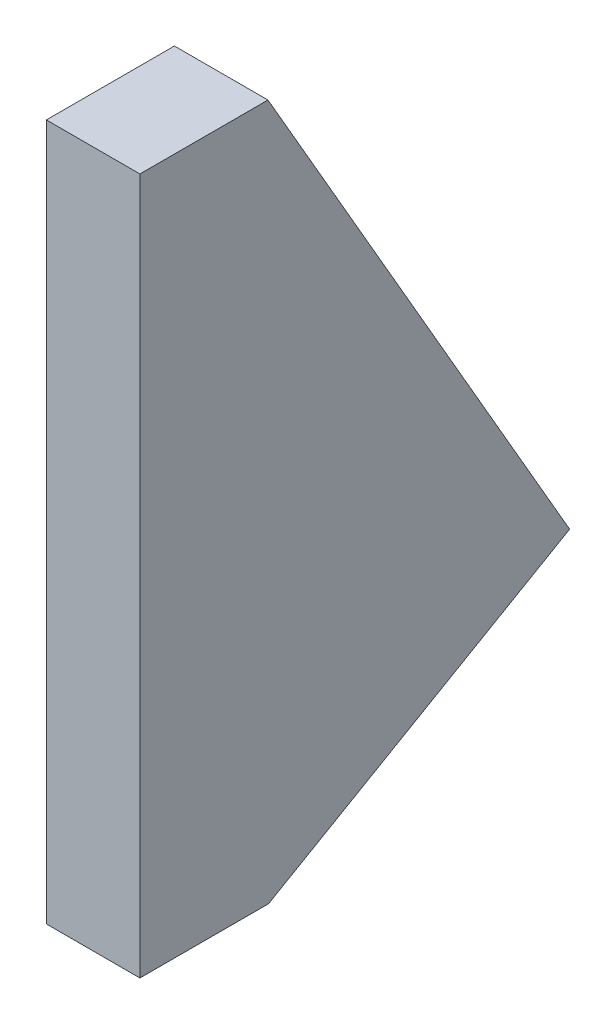
from build123d import *

# Parameters (mm, degrees)
BOSS_EXTRUDE1_DEPTH = 3.175


with BuildPart() as part:
    # Sketch1 → Boss-Extrude1 (new body)
    with BuildSketch(Plane(origin=(0, 0, 0), x_dir=(0, 0, -1), z_dir=(1, 0, 0))):
        Polygon((4.427985226, -11.81399897), (14.644473227, -5.915506869), (4.408338258, 11.81399897), (0.0635, 11.81399897), (0.0635, -11.81399897), align=None)
    extrude(amount=BOSS_EXTRUDE1_DEPTH)


solid = part.part
